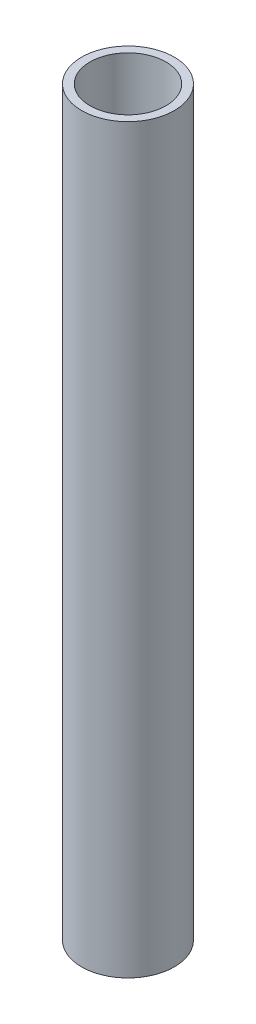
from build123d import *

# Parameters (mm, degrees)
SKETCH1_R           = 12.7
SKETCH1_R_2         = 10.414
BOSS_EXTRUDE1_DEPTH = 203.2


with BuildPart() as part:
    # Sketch1 → Boss-Extrude1 (new body)
    with BuildSketch(Plane(origin=(0, 0, 0), x_dir=(1, 0, 0), z_dir=(0, 1, 0))):
        Circle(SKETCH1_R)
        Circle(SKETCH1_R_2, mode=Mode.SUBTRACT)
    extrude(amount=BOSS_EXTRUDE1_DEPTH)


solid = part.part
